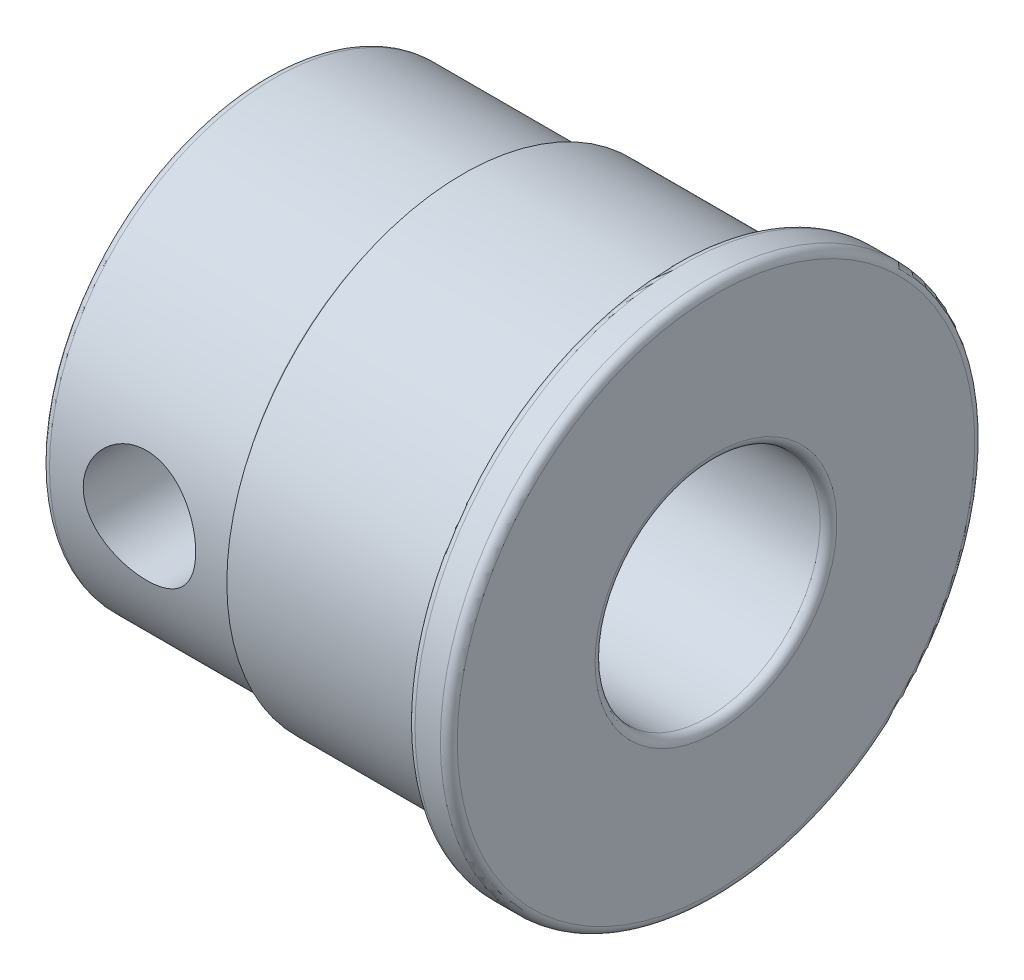
from build123d import *

# Parameters (mm, degrees)
FILLET1_R               = 0.3
SKETCH2_R               = 2
CUT_EXTRUDE1_DEPTH      = 10.5
CUT_EXTRUDE1_DEPTH_BACK = 10.5


with BuildPart() as part:
    # Sketch1 → Revolve1 (revolve)
    with BuildSketch(Plane(origin=(0, 0, 0), x_dir=(1, 0, 0), z_dir=(0, 1, 0))):
        Polygon((0, 4), (0, 8), (7, 8), (7, 8.39378315), (14.5, 8.39378315), (14.5, 9.5), (16, 9.5), (16, 4), align=None)
    revolve(axis=Axis((0, 0, 0), (1, 0, 0)))

    # Fillet1
    fillet1_edges = [part.edges().sort_by_distance(p)[0] for p in [
        (0, 0, 4),
        (16, 0, 4),
        (16, 0, 9.5),
        (14.5, 0, 9.5),
        (7, 0, 8),
        (0, 0, 8),
    ]]
    fillet(fillet1_edges, radius=FILLET1_R)

    # Sketch2 → Cut-Extrude1 (cut, two sides)
    with BuildSketch(Plane.XY) as cut_extrude1_sk:
        with Locations((3.5, 0)):
            Circle(SKETCH2_R)
    extrude(amount=CUT_EXTRUDE1_DEPTH, mode=Mode.SUBTRACT)
    extrude(cut_extrude1_sk.sketch, amount=-CUT_EXTRUDE1_DEPTH_BACK, mode=Mode.SUBTRACT)


solid = part.part
